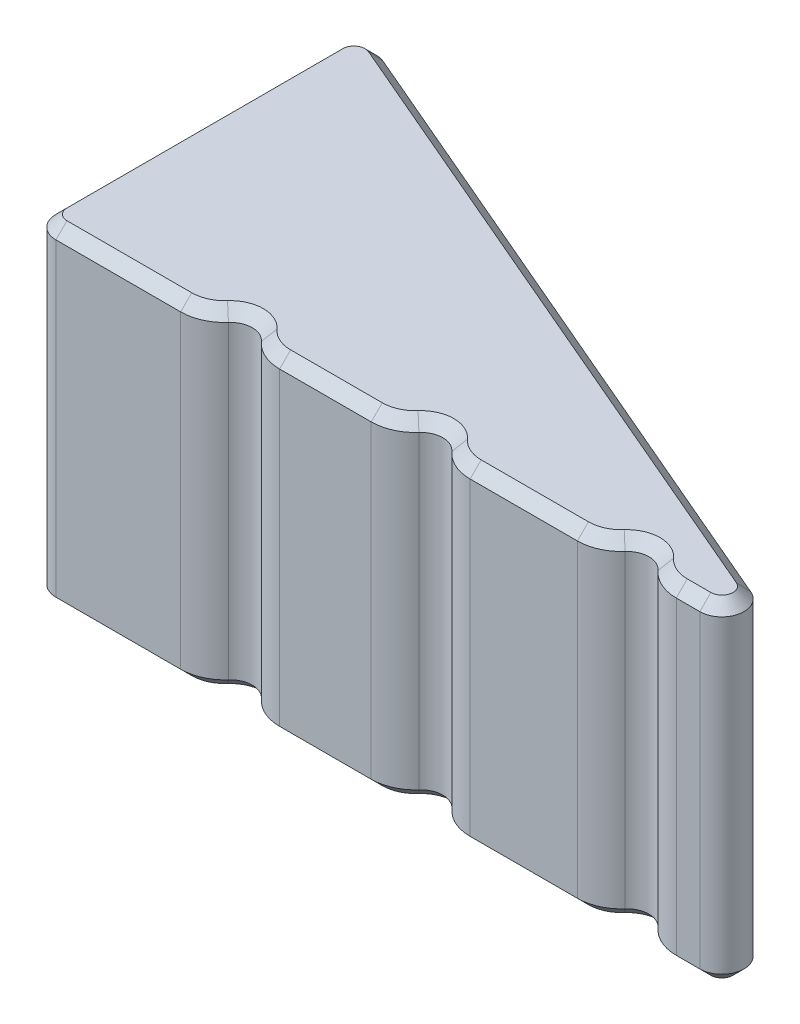
from build123d import *

# Parameters (mm, degrees)
BOSS_EXTRUDE1_DEPTH = 37.5
FILLET1_R           = 5
CHAMFER1_SIZE       = 2.5


with BuildPart() as part:
    # Sketch1 → Boss-Extrude1 (new body, symmetric)
    with BuildSketch(Plane(origin=(0, 0, 0), x_dir=(1, 0, 0), z_dir=(0, 1, 0))):
        with BuildLine():
            Line((-97.927346189, 41.968862652), (77.072653811, -33.031137348))
            Line((77.072653811, -33.031137348), (47.38494666, -33.031137348))
            ThreePointArc((47.38494666, -33.031137348), (43.302463755, -32.159846639), (39.931386735, -29.697804014))
            ThreePointArc((39.931386735, -29.697804014), (36.204606772, -28.031137348), (32.47782681, -29.697804014))
            ThreePointArc((32.47782681, -29.697804014), (29.106749789, -32.159846639), (25.024266885, -33.031137348))
            Line((25.024266885, -33.031137348), (0.752993699, -33.031137348))
            ThreePointArc((0.752993699, -33.031137348), (-3.329489206, -32.159846639), (-6.700566226, -29.697804014))
            ThreePointArc((-6.700566226, -29.697804014), (-10.427346189, -28.031137348), (-14.154126151, -29.697804014))
            ThreePointArc((-14.154126151, -29.697804014), (-17.525203172, -32.159846639), (-21.607686076, -33.031137348))
            Line((-21.607686076, -33.031137348), (-42.33546369, -33.031137348))
            ThreePointArc((-42.33546369, -33.031137348), (-46.417946594, -32.159846639), (-49.789023615, -29.697804014))
            ThreePointArc((-49.789023615, -29.697804014), (-53.515803577, -28.031137348), (-57.24258354, -29.697804014))
            ThreePointArc((-57.24258354, -29.697804014), (-60.61366056, -32.159846639), (-64.696143465, -33.031137348))
            Line((-64.696143465, -33.031137348), (-97.927346189, -33.031137348))
            Line((-97.927346189, -33.031137348), (-97.927346189, 41.968862652))
        make_face()
    extrude(amount=BOSS_EXTRUDE1_DEPTH, both=True)

    # Fillet1
    fillet1_edges = [part.edges().sort_by_distance(p)[0] for p in [
        (-97.927346189, 0, 33.031137348),
        (-97.927346189, 0, -41.968862652),
        (77.072653811, 0, 33.031137348),
    ]]
    fillet(fillet1_edges, radius=FILLET1_R)

    # Chamfer1
    chamfer1_edges = [part.edges().sort_by_distance(p)[0] for p in [
        (43.302463755, -37.5, 32.159846639),
        (36.204606772, -37.5, 28.031137348),
        (29.106749789, -37.5, 32.159846639),
        (12.888630292, -37.5, 33.031137348),
        (-3.329489206, -37.5, 32.159846639),
        (-10.427346189, -37.5, 28.031137348),
        (-17.525203172, -37.5, 32.159846639),
        (-31.971574883, -37.5, 33.031137348),
        (-46.417946594, -37.5, 32.159846639),
        (-53.515803577, -37.5, 28.031137348),
        (-60.61366056, -37.5, 32.159846639),
        (50.048989314, -37.5, 33.031137348),
        (-60.61366056, 37.5, 32.159846639),
        (-53.515803577, 37.5, 28.031137348),
        (-46.417946594, 37.5, 32.159846639),
        (-31.971574883, 37.5, 33.031137348),
        (-17.525203172, 37.5, 32.159846639),
        (-10.427346189, 37.5, 28.031137348),
        (-18.137560617, -37.5, -7.773240265),
        (-18.137560617, 37.5, -7.773240265),
        (-3.329489206, 37.5, 32.159846639),
        (-78.811744827, -37.5, 33.031137348),
        (-97.927346189, -37.5, -3.177515114),
        (-95.679801232, -37.5, -38.560373038),
        (-96.462880095, -37.5, 31.566671254),
        (57.610920582, -37.5, 29.036466709),
        (-97.927346189, 37.5, -3.177515114),
        (12.888630292, 37.5, 33.031137348),
        (-78.811744827, 37.5, 33.031137348),
        (-95.679801232, 37.5, -38.560373038),
        (-96.462880095, 37.5, 31.566671254),
        (50.048989314, 37.5, 33.031137348),
        (57.610920582, 37.5, 29.036466709),
        (29.106749789, 37.5, 32.159846639),
        (36.204606772, 37.5, 28.031137348),
        (43.302463755, 37.5, 32.159846639),
    ]]
    chamfer(chamfer1_edges, length=CHAMFER1_SIZE)


solid = part.part
